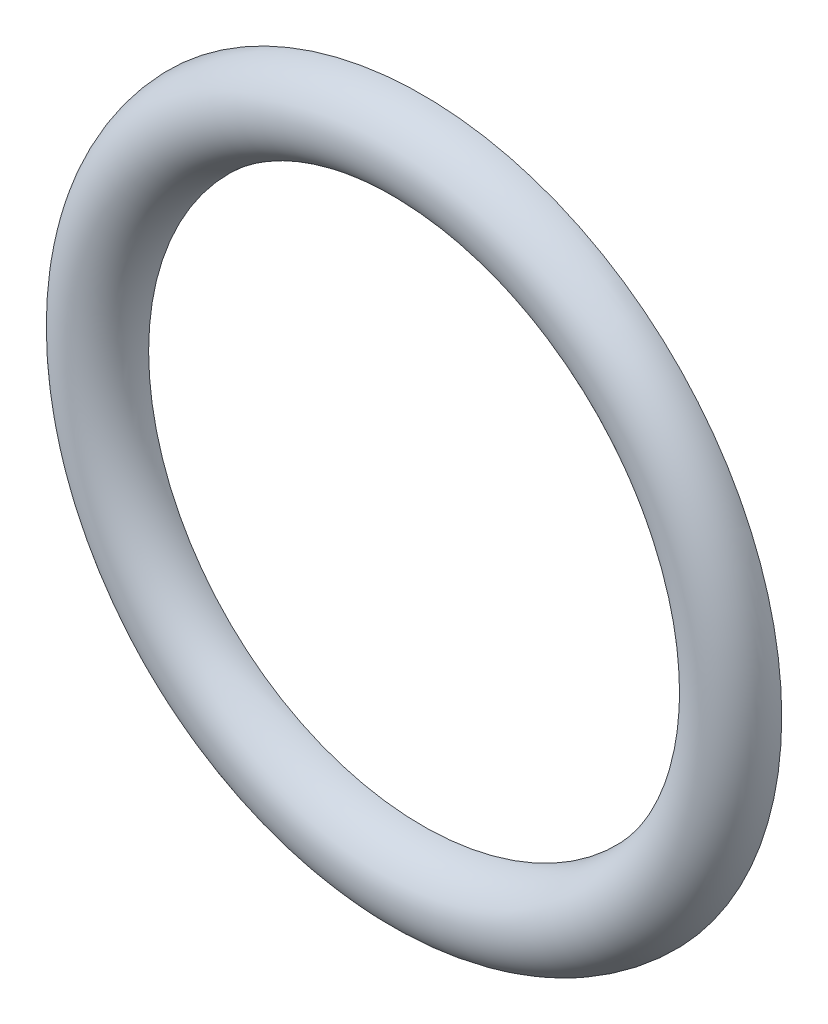
from build123d import *


with BuildPart() as part:
    # Sketch1 → Revolve1 (revolve)
    with BuildSketch(Plane(origin=(0, 0, 0), x_dir=(1, 0, 0), z_dir=(0, 1, 0))):
        with BuildLine():
            Line((38.092105263, 0), (68.092105263, 0))
            ThreePointArc((68.092105263, 0), (53.092105263, -15), (38.092105263, 0))
        make_face()
    revolve(axis=Axis((-58.907894737, 0, -53.117687897), (0, 0, 1)))


solid = part.part
